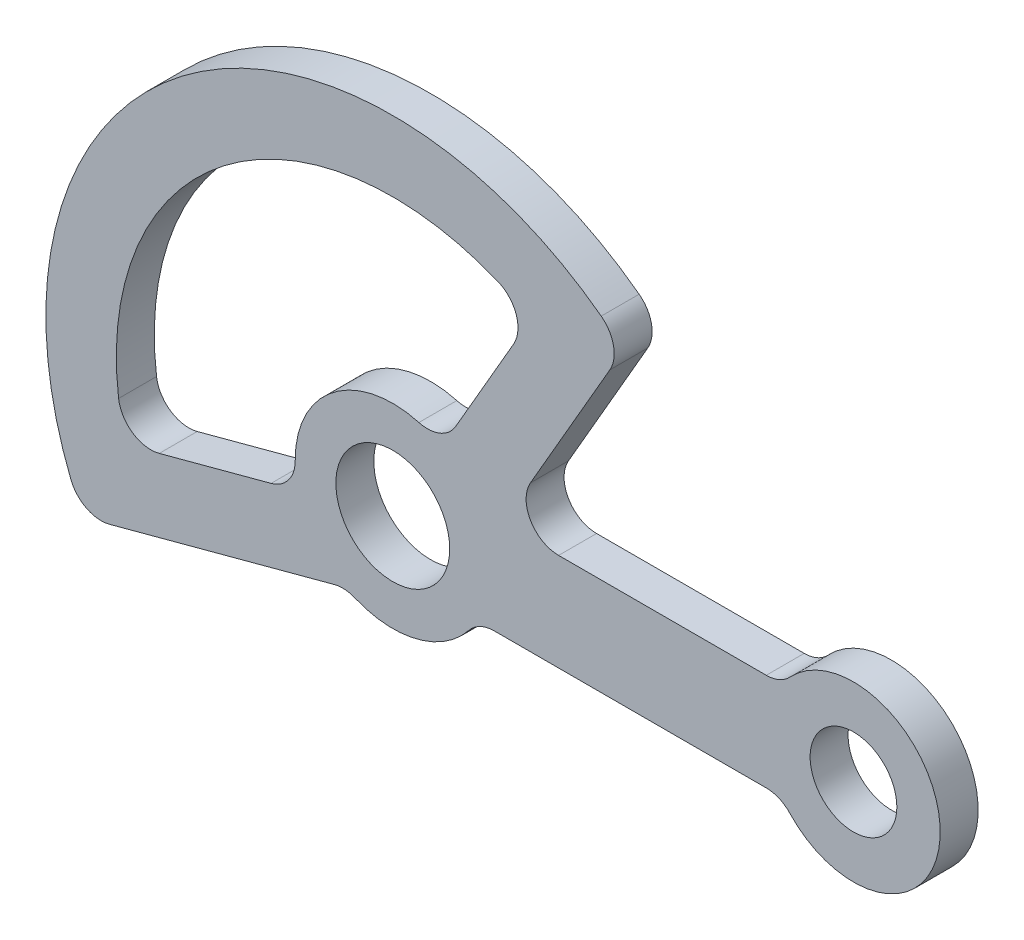
from build123d import *

# Parameters (mm, degrees)
SKETCH1_R           = 10.5
SKETCH1_R_2         = 8
BOSS_EXTRUDE2_DEPTH = 7
FILLET4_R           = 6
FILLET5_R           = 6


with BuildPart() as part:
    # Sketch1 → Boss-Extrude2 (new body)
    with BuildSketch(Plane.XY):
        with BuildLine():
            Line((71.771243445, 9), (20.207259422, 9))
            Line((20.207259422, 9), (42.591220317, 47.770157545))
            ThreePointArc((42.591220317, 47.770157545), (-38.960731457, 50.774613779), (-57.165847871, -28.776133117))
            Line((-57.165847871, -28.776133117), (-8.66103197, -15.779306867))
            ThreePointArc((-8.66103197, -15.779306867), (4.846344572, -17.335309178), (15.588457268, -9))
            Line((15.588457268, -9), (71.771243445, -9))
            ThreePointArc((71.771243445, -9), (101, 0), (71.771243445, 9))
        make_face()
        Circle(SKETCH1_R, mode=Mode.SUBTRACT)
        with Locations((85, 0)):
            Circle(SKETCH1_R_2, mode=Mode.SUBTRACT)
        with BuildLine():
            Line((9, 15.588457268), (25.5, 44.167295593))
            ThreePointArc((25.5, 44.167295593), (-31.046832879, 40.461020355), (-49.262217141, -13.1997713))
            Line((-49.262217141, -13.1997713), (-17.386664873, -4.658742812))
            ThreePointArc((-17.386664873, -4.658742812), (-10.957705722, 14.280360125), (9, 15.588457268))
        make_face(mode=Mode.SUBTRACT)
    extrude(amount=BOSS_EXTRUDE2_DEPTH)

    # Fillet4
    fillet4_edges = [part.edges().sort_by_distance(p)[0] for p in [
        (71.771243445, -9, 3.5),
        (15.588457268, -9, 3.5),
        (-8.66103197, -15.779306867, 3.5),
        (-57.165847871, -28.776133117, 3.5),
        (42.591220317, 47.770157545, 3.5),
        (20.207259422, 9, 3.5),
        (71.771243445, 9, 3.5),
    ]]
    fillet(fillet4_edges, radius=FILLET4_R)

    # Fillet5
    fillet5_edges = [part.edges().sort_by_distance(p)[0] for p in [
        (25.5, 44.167295593, 3.5),
        (-49.262217141, -13.1997713, 3.5),
        (-17.386664873, -4.658742812, 3.5),
        (9, 15.588457268, 3.5),
    ]]
    fillet(fillet5_edges, radius=FILLET5_R)


solid = part.part
